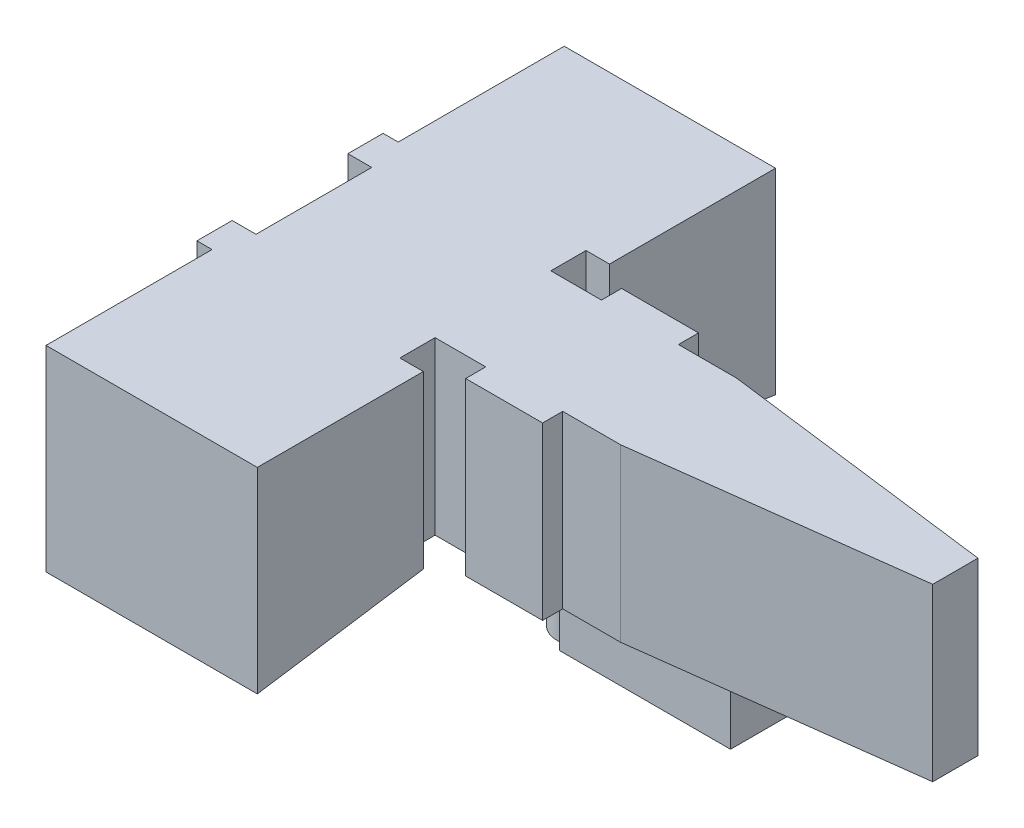
from build123d import *

# Parameters (mm, degrees)
BOSS_EXTRUDE1_DEPTH = 17
BOSS_EXTRUDE2_DEPTH = 6.25
BOSS_EXTRUDE3_DEPTH = 21


with BuildPart() as part:
    # Sketch1 → Boss-Extrude1 (new body)
    with BuildSketch(Plane(origin=(0, 0, 0), x_dir=(1, 0, 0), z_dir=(0, 1, 0))):
        Polygon((38.887869235, 32.64650928), (33.855356453, 32.64650928), (33.855356453, 36.14650928), (36.187130568, 36.14650928), (36.187130568, 52.64650928), (15.187130568, 52.64650928), (15.187130568, 36.14650928), (13.687130568, 36.14650928), (13.687130568, 32.64650928), (16.05811547, 32.64650928), (16.05811547, 21.14650928), (13.687130568, 21.14650928), (13.687130568, 17.64650928), (15.187130568, 17.64650928), (15.187130568, 1.14650928), (36.187130568, 1.14650928), (36.187130568, 17.64650928), (33.855356453, 17.64650928), (33.855356453, 21.14650928), (38.887869235, 21.14650928), (38.887869235, 19.14650928), (46.537869235, 19.14650928), (46.537869235, 21.14650928), (52.287869235, 21.14650928), (79.808081842, 24.64650928), (79.808081842, 29.14650928), (52.287869235, 32.64650928), (46.537869235, 32.64650928), (46.537869235, 34.64650928), (38.887869235, 34.64650928), align=None)
    extrude(amount=BOSS_EXTRUDE1_DEPTH)

    # Sketch2 → Boss-Extrude2 (add)
    with BuildSketch(Plane.XZ):
        with BuildLine():
            Line((43.712869235, -29.187797128), (43.712869235, -30.14650928))
            Line((43.712869235, -30.14650928), (45.212869235, -30.14650928))
            Line((45.212869235, -30.14650928), (60.712869235, -30.14650928))
            Line((60.712869235, -30.14650928), (60.712869235, -26.89650928))
            Line((60.712869235, -26.89650928), (60.712869235, -23.64650928))
            Line((60.712869235, -23.64650928), (45.212869235, -23.64650928))
            Line((45.212869235, -23.64650928), (43.712869235, -23.64650928))
            Line((43.712869235, -23.64650928), (43.712869235, -24.605221433))
            ThreePointArc((43.712869235, -24.605221433), (40.212869235, -26.89650928), (43.712869235, -29.187797128))
        make_face()
    extrude(amount=BOSS_EXTRUDE2_DEPTH)

    # Sketch3 → Boss-Extrude3 (add)
    with BuildSketch(Plane.ZY.offset(-15.187130568)):
        Polygon((-1.14650928, 0), (-1.14650928, -2.5), (-17.64650928, 0), align=None)
        Polygon((-36.14650928, 0), (-52.64650928, 0), (-52.64650928, -2.5), align=None)
    extrude(amount=-BOSS_EXTRUDE3_DEPTH)


solid = part.part
